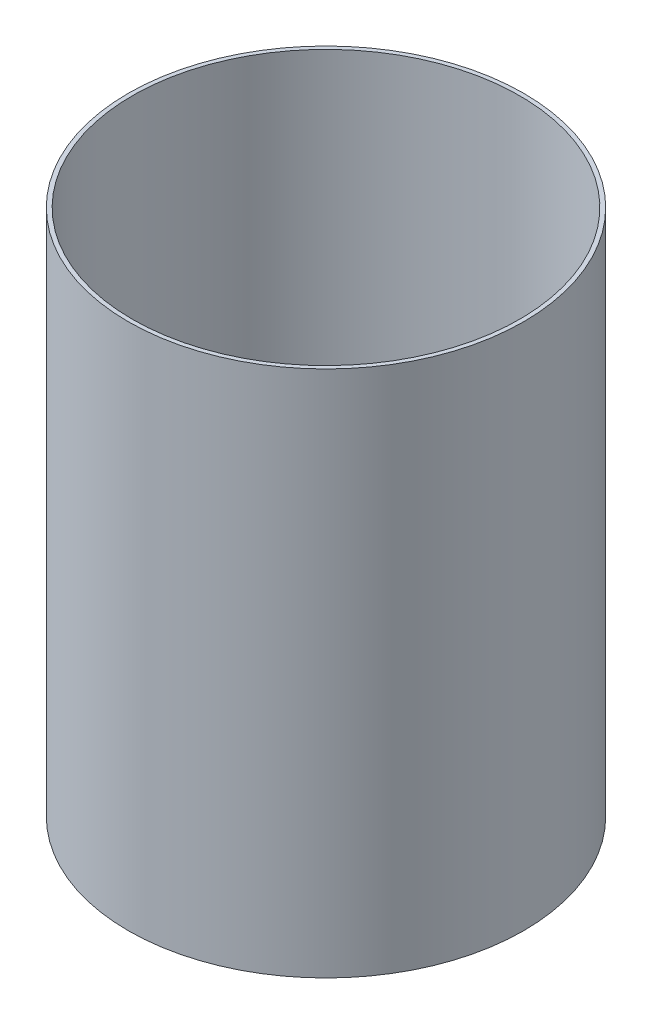
from build123d import *

# Parameters (mm, degrees)
SKETCH1_R           = 152.4
SKETCH1_R_2         = 149.225
BOSS_EXTRUDE1_DEPTH = 406.4


with BuildPart() as part:
    # Sketch1 → Boss-Extrude1 (new body)
    with BuildSketch(Plane(origin=(0, 0, 0), x_dir=(1, 0, 0), z_dir=(0, 1, 0))):
        Circle(SKETCH1_R)
        Circle(SKETCH1_R_2, mode=Mode.SUBTRACT)
    extrude(amount=BOSS_EXTRUDE1_DEPTH)


solid = part.part
